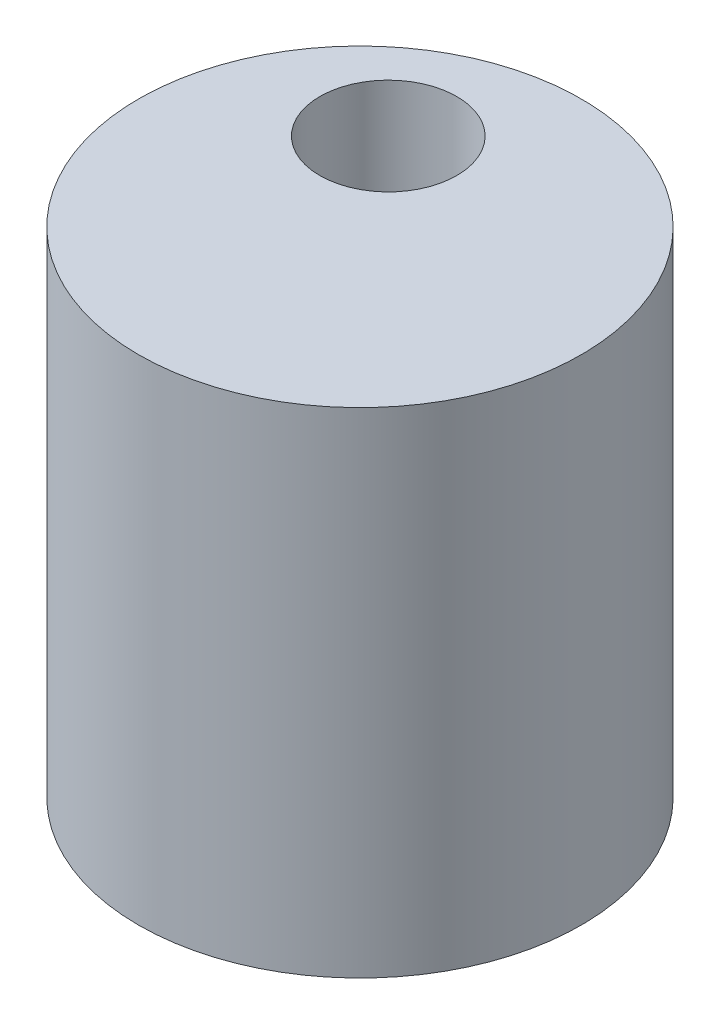
from build123d import *

# Parameters (mm, degrees)
SKETCH1_R           = 13.0937
SKETCH1_R_2         = 4.05
BOSS_EXTRUDE1_DEPTH = 29.21


with BuildPart() as part:
    # Sketch1 → Boss-Extrude1 (new body)
    with BuildSketch(Plane(origin=(0, 0, 0), x_dir=(1, 0, 0), z_dir=(0, 1, 0))):
        Circle(SKETCH1_R)
        with Locations((-3.81, 5.4864)):
            Circle(SKETCH1_R_2, mode=Mode.SUBTRACT)
    extrude(amount=-BOSS_EXTRUDE1_DEPTH)


solid = part.part
